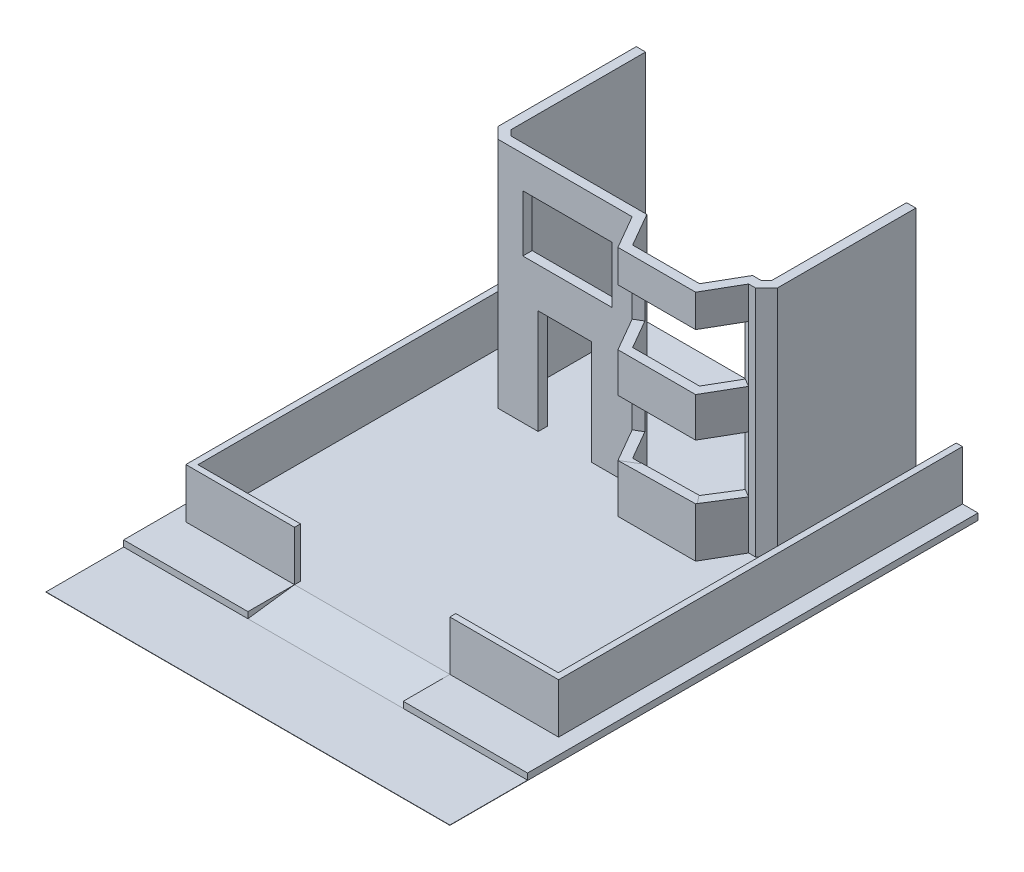
from build123d import *

# Parameters (mm, degrees)
CROQUIS1_W              = 13000
CROQUIS1_H              = 17000
SALIENTE_EXTRUIR1_DEPTH = 10
CROQUIS2_W              = 13000
CROQUIS2_H              = 14500
SALIENTE_EXTRUIR2_DEPTH = 200
CROQUIS4_W              = 12000
CROQUIS4_H              = 11500
CROQUIS4_W_2            = 11600
CROQUIS4_H_2            = 11116.666666
SALIENTE_EXTRUIR4_DEPTH = 1600
CROQUIS5_W              = 5000
CROQUIS5_H              = 1600
CORTAR_EXTRUIR1_DEPTH   = 191.666667
CROQUIS7_W              = 11600
CROQUIS7_H              = 1600
CORTAR_EXTRUIR2_DEPTH   = 191.666667
CROQUIS8_W              = 5000
CROQUIS8_H              = 1500
CORTAR_EXTRUIR3_DEPTH   = 200
SALIENTE_EXTRUIR5_DEPTH = 5000
SALIENTE_EXTRUIR6_DEPTH = 7500
CROQUIS11_W             = 200
CROQUIS11_H             = 1600
SALIENTE_EXTRUIR7_DEPTH = 1500
CROQUIS12_W             = 1717.047722
CROQUIS12_H             = 3362.825557
CORTAR_EXTRUIR4_DEPTH   = 4809.333333
CORTAR_EXTRUIR5_DEPTH   = 5891.865088
CORTAR_EXTRUIR6_DEPTH   = 690
CROQUIS15_W             = 1250
CROQUIS15_H             = 1816.080564
CORTAR_EXTRUIR7_DEPTH   = 540
CROQUIS16_W             = 2500
CROQUIS16_H             = 1810
CORTAR_EXTRUIR8_DEPTH   = 540
CROQUIS17_W             = 1250
CROQUIS17_H             = 1810
CORTAR_EXTRUIR9_DEPTH   = 540
CROQUIS18_W             = 1250
CROQUIS18_H             = 1810
CORTAR_EXTRUIR10_DEPTH  = 540
CROQUIS19_W             = 2864.930734
CROQUIS19_H             = 1817.968628
CORTAR_EXTRUIR11_DEPTH  = 540


with BuildPart() as part:
    # Croquis1 → Saliente-Extruir1 (new body)
    with BuildSketch(Plane(origin=(0, 0, 0), x_dir=(1, 0, 0), z_dir=(0, 1, 0))):
        Rectangle(CROQUIS1_W, CROQUIS1_H)
    extrude(amount=SALIENTE_EXTRUIR1_DEPTH)

    # Croquis2 → Saliente-Extruir2 (add)
    with BuildSketch(Plane(origin=(0, 10, 0), x_dir=(1, 0, 0), z_dir=(0, 1, 0))):
        with Locations((0, 1250)):
            Rectangle(CROQUIS2_W, CROQUIS2_H)
    extrude(amount=SALIENTE_EXTRUIR2_DEPTH)

    # Croquis4 → Saliente-Extruir4 (add)
    with BuildSketch(Plane(origin=(0, 210, 0), x_dir=(1, 0, 0), z_dir=(0, 1, 0))):
        with Locations((0, 1250)):
            Rectangle(CROQUIS4_W, CROQUIS4_H)
        with Locations((0, 1250)):
            Rectangle(CROQUIS4_W_2, CROQUIS4_H_2, mode=Mode.SUBTRACT)
    extrude(amount=SALIENTE_EXTRUIR4_DEPTH)

    # Croquis5 → Cortar-Extruir1 (cut)
    with BuildSketch(Plane.XY.offset(4500)):
        with Locations((0, 1010)):
            Rectangle(CROQUIS5_W, CROQUIS5_H)
    extrude(amount=-CORTAR_EXTRUIR1_DEPTH, mode=Mode.SUBTRACT)

    # Croquis7 → Cortar-Extruir2 (cut)
    with BuildSketch(Plane.XY.offset(-6808.333333)):
        with Locations((0, 1010)):
            Rectangle(CROQUIS7_W, CROQUIS7_H)
    extrude(amount=-CORTAR_EXTRUIR2_DEPTH, mode=Mode.SUBTRACT)

    # Croquis8 → Cortar-Extruir3 (cut)
    with BuildSketch(Plane(origin=(0, 210, 0), x_dir=(1, 0, 0), z_dir=(0, 1, 0))):
        with Locations((0, -5250)):
            Rectangle(CROQUIS8_W, CROQUIS8_H)
    extrude(amount=-CORTAR_EXTRUIR3_DEPTH, mode=Mode.SUBTRACT)

    # Croquis9 → Saliente-Extruir5 (add)
    with BuildSketch(Plane(origin=(-2500, 0, 0), x_dir=(0, 0, -1), z_dir=(1, 0, 0))):
        Polygon((-6000, 10), (-4500, 10), (-4500, 210), align=None)
    extrude(amount=SALIENTE_EXTRUIR5_DEPTH)

    # Croquis10 → Saliente-Extruir6 (add)
    with BuildSketch(Plane(origin=(0, 210, 0), x_dir=(1, 0, 0), z_dir=(0, 1, 0))):
        Polygon((-4146.446609, 3691.666667), (175.811733, 3691.666667), (800.811733, 2609.134912), (3300.811733, 2609.134912), (3925.811733, 3691.666667), (4146.446609, 3691.666667), (4500, 4045.220057), (4500, 8500), (4200, 8500), (4200, 4169.484126), (4022.182541, 3991.666667), (3752.606652, 3991.666667), (3127.606652, 2909.134912), (974.016813, 2909.134912), (349.016813, 3991.666667), (-4022.182541, 3991.666667), (-4200, 4169.484126), (-4200, 8500), (-4500, 8500), (-4500, 4045.220057), align=None)
    extrude(amount=SALIENTE_EXTRUIR6_DEPTH)

    # Croquis11 → Saliente-Extruir7 (add)
    with BuildSketch(Plane(origin=(0, 0, -7000), x_dir=(-1, 0, 0), z_dir=(0, 0, -1))):
        with Locations((-5900, 1010)):
            Rectangle(CROQUIS11_W, CROQUIS11_H)
        with Locations((5900, 1010)):
            Rectangle(CROQUIS11_W, CROQUIS11_H)
    extrude(amount=SALIENTE_EXTRUIR7_DEPTH)

    # Croquis12 → Cortar-Extruir4 (cut, through all)
    with BuildSketch(Plane.XY.offset(-3691.666667)):
        with Locations((-1988.473814, 1891.412778)):
            Rectangle(CROQUIS12_W, CROQUIS12_H)
    extrude(amount=-CORTAR_EXTRUIR4_DEPTH, mode=Mode.SUBTRACT)

    # Croquis13 → Cortar-Extruir5 (cut, through all)
    with BuildSketch(Plane.XY.offset(-2609.134912)):
        Polygon((800.811733, 1769.030306), (3320.826711, 1810), (3300.811733, 3585.11087), (800.811733, 3585.11087), align=None)
    extrude(amount=-CORTAR_EXTRUIR5_DEPTH, mode=Mode.SUBTRACT)

    # Croquis14 → Cortar-Extruir6 (cut, symmetric)
    with BuildSketch(Plane(origin=(1345.820242, 0, 777.009679), x_dir=(0.5, 0, -0.866025), z_dir=(0.866025, 0, 0.5))):
        Polygon((3909.982982, 3585.11087), (5159.982982, 3585.11087), (5159.982982, 1776.384445), (3950.012938, 1810), align=None)
    extrude(amount=CORTAR_EXTRUIR6_DEPTH, both=True, mode=Mode.SUBTRACT)

    # Croquis15 → Cortar-Extruir7 (cut)
    with BuildSketch(Plane(origin=(1730.397357, 0, -999.04538), x_dir=(0.5, 0, 0.866025), z_dir=(-0.866025, 0, 0.5))):
        with Locations((-2484.171249, 2677.070588)):
            Rectangle(CROQUIS15_W, CROQUIS15_H)
    extrude(amount=-CORTAR_EXTRUIR7_DEPTH, mode=Mode.SUBTRACT)

    # Croquis16 → Cortar-Extruir8 (cut)
    with BuildSketch(Plane.XY.offset(-2609.134912)):
        with Locations((2050.811733, 5760.648602)):
            Rectangle(CROQUIS16_W, CROQUIS16_H)
    extrude(amount=-CORTAR_EXTRUIR8_DEPTH, mode=Mode.SUBTRACT)

    # Croquis17 → Cortar-Extruir9 (cut)
    with BuildSketch(Plane(origin=(1345.820242, 0, 777.009679), x_dir=(0.5, 0, -0.866025), z_dir=(0.866025, 0, 0.5))):
        with Locations((4534.982982, 5760.648602)):
            Rectangle(CROQUIS17_W, CROQUIS17_H)
    extrude(amount=-CORTAR_EXTRUIR9_DEPTH, mode=Mode.SUBTRACT)

    # Croquis18 → Cortar-Extruir10 (cut)
    with BuildSketch(Plane(origin=(1730.397357, 0, -999.04538), x_dir=(0.5, 0, 0.866025), z_dir=(-0.866025, 0, 0.5))):
        with Locations((-2484.171249, 5760.648602)):
            Rectangle(CROQUIS18_W, CROQUIS18_H)
    extrude(amount=-CORTAR_EXTRUIR10_DEPTH, mode=Mode.SUBTRACT)

    # Croquis19 → Cortar-Extruir11 (cut)
    with BuildSketch(Plane.XY.offset(-3691.666667)):
        with Locations((-1911.341657, 5764.632916)):
            Rectangle(CROQUIS19_W, CROQUIS19_H)
    extrude(amount=-CORTAR_EXTRUIR11_DEPTH, mode=Mode.SUBTRACT)


solid = part.part
